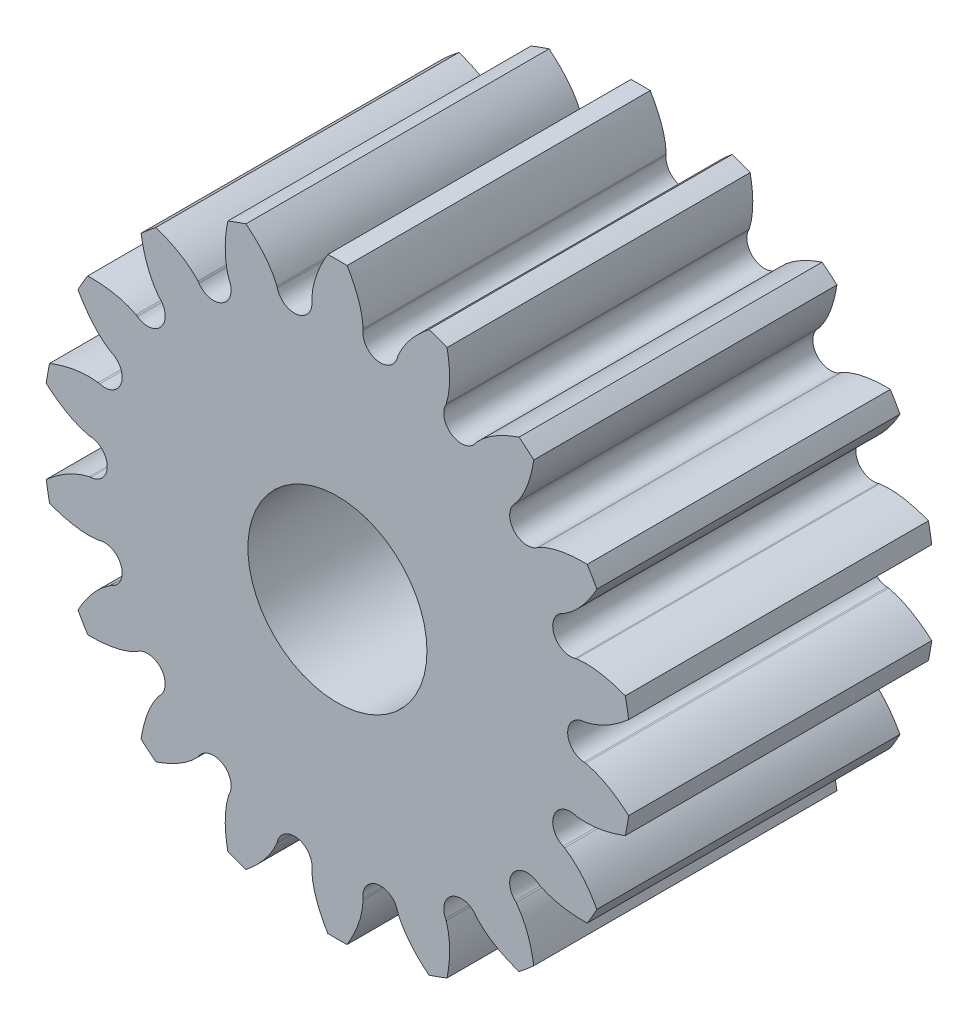
from build123d import *

# Parameters (mm, degrees)
SKETCH3_R                           = 2.286
SKETCH3_R_2                         = 0.889
BASE_DEPTH                          = 3.0099
HALF_TOOTH_DEPTH                    = 3.0099
PATTERN_OF_HALF_TOOTH_COUNT         = 18
PATTERN_OF_HALF_TOOTH_COPY_1_DEPTH  = 3.0099
PATTERN_OF_HALF_TOOTH_COPY_2_DEPTH  = 3.0099
PATTERN_OF_HALF_TOOTH_COPY_3_DEPTH  = 3.0099
PATTERN_OF_HALF_TOOTH_COPY_4_DEPTH  = 3.0099
PATTERN_OF_HALF_TOOTH_COPY_5_DEPTH  = 3.0099
PATTERN_OF_HALF_TOOTH_COPY_6_DEPTH  = 3.0099
PATTERN_OF_HALF_TOOTH_COPY_7_DEPTH  = 3.0099
PATTERN_OF_HALF_TOOTH_COPY_8_DEPTH  = 3.0099
PATTERN_OF_HALF_TOOTH_COPY_9_DEPTH  = 3.0099
PATTERN_OF_HALF_TOOTH_COPY_10_DEPTH = 3.0099
PATTERN_OF_HALF_TOOTH_COPY_11_DEPTH = 3.0099
PATTERN_OF_HALF_TOOTH_COPY_12_DEPTH = 3.0099
PATTERN_OF_HALF_TOOTH_COPY_13_DEPTH = 3.0099
PATTERN_OF_HALF_TOOTH_COPY_14_DEPTH = 3.0099
PATTERN_OF_HALF_TOOTH_COPY_15_DEPTH = 3.0099
PATTERN_OF_HALF_TOOTH_COPY_16_DEPTH = 3.0099
PATTERN_OF_HALF_TOOTH_COPY_17_DEPTH = 3.0099


with BuildPart() as part:
    # Sketch3 → Base (new body)
    with BuildSketch(Plane.XY):
        Circle(SKETCH3_R)
        Circle(SKETCH3_R_2, mode=Mode.SUBTRACT)
    extrude(amount=BASE_DEPTH)

    # Sketch2 → Half tooth (add)
    with BuildSketch(Plane.XY):
        with BuildLine():
            Line((0, 2.921), (0, 2.286))
            ThreePointArc((0, 2.286), (0.199238028, 2.27730108), (0.396959734, 2.251270523))
            ThreePointArc((0.396959734, 2.251270523), (0.28773176, 2.318156306), (0.253382626, 2.441544292))
            Line((0.253382626, 2.441544292), (0.255003353, 2.457161288))
            add(Edge.make_bspline(
                [(0.255003353, 2.457161288), (0.25245669, 2.511970923), (0.22493294, 2.674677864), (0.152013752, 2.825486334), (0.095650308, 2.91943351)],
                knots=[0, 0, 0, 0, 0.332628043, 1, 1, 1, 1], degree=3))
            ThreePointArc((0.095650308, 2.91943351), (0.047831567, 2.920608351), (0, 2.921))
        make_face()
    half_tooth = extrude(amount=HALF_TOOTH_DEPTH)

    # Mirror of half tooth: Half tooth across plane
    add(half_tooth.mirror(Plane.ZY))

    # Pattern of half tooth: Half tooth ×18 about axis
    pattern_of_half_tooth_axis = Axis((0, 0, 3.0099), (0, 0, 1))
    for i in range(1, PATTERN_OF_HALF_TOOTH_COUNT):
        add(half_tooth.rotate(pattern_of_half_tooth_axis, i * 360 / PATTERN_OF_HALF_TOOTH_COUNT))

    # Pattern of half tooth copy 1 sketch → Pattern of half tooth copy 1 (add)
    with BuildSketch(Plane(origin=(0, 0, 0), x_dir=(-0.939692621, -0.342020143, 0), z_dir=(0, 0, 1))):
        with BuildLine():
            Line((0, -2.921), (0, -2.286))
            ThreePointArc((0, -2.286), (0.199238028, -2.27730108), (0.396959734, -2.251270523))
            ThreePointArc((0.396959734, -2.251270523), (0.28773176, -2.318156306), (0.253382626, -2.441544292))
            Line((0.253382626, -2.441544292), (0.255003353, -2.457161288))
            add(Edge.make_bspline(
                [(0.255003353, -2.457161288), (0.25245669, -2.511970923), (0.22493294, -2.674677864), (0.152013752, -2.825486334), (0.095650308, -2.91943351)],
                knots=[0, 0, 0, 0, 0.332628043, 1, 1, 1, 1], degree=3))
            ThreePointArc((0.095650308, -2.91943351), (0.047831567, -2.920608351), (0, -2.921))
        make_face()
    extrude(amount=PATTERN_OF_HALF_TOOTH_COPY_1_DEPTH)

    # Pattern of half tooth copy 2 sketch → Pattern of half tooth copy 2 (add)
    with BuildSketch(Plane(origin=(0, 0, 0), x_dir=(-0.766044443, -0.64278761, 0), z_dir=(0, 0, 1))):
        with BuildLine():
            Line((0, -2.921), (0, -2.286))
            ThreePointArc((0, -2.286), (0.199238028, -2.27730108), (0.396959734, -2.251270523))
            ThreePointArc((0.396959734, -2.251270523), (0.28773176, -2.318156306), (0.253382626, -2.441544292))
            Line((0.253382626, -2.441544292), (0.255003353, -2.457161288))
            add(Edge.make_bspline(
                [(0.255003353, -2.457161288), (0.25245669, -2.511970923), (0.22493294, -2.674677864), (0.152013752, -2.825486334), (0.095650308, -2.91943351)],
                knots=[0, 0, 0, 0, 0.332628043, 1, 1, 1, 1], degree=3))
            ThreePointArc((0.095650308, -2.91943351), (0.047831567, -2.920608351), (0, -2.921))
        make_face()
    extrude(amount=PATTERN_OF_HALF_TOOTH_COPY_2_DEPTH)

    # Pattern of half tooth copy 3 sketch → Pattern of half tooth copy 3 (add)
    with BuildSketch(Plane(origin=(0, 0, 0), x_dir=(-0.5, -0.866025404, 0), z_dir=(0, 0, 1))):
        with BuildLine():
            Line((0, -2.921), (0, -2.286))
            ThreePointArc((0, -2.286), (0.199238028, -2.27730108), (0.396959734, -2.251270523))
            ThreePointArc((0.396959734, -2.251270523), (0.28773176, -2.318156306), (0.253382626, -2.441544292))
            Line((0.253382626, -2.441544292), (0.255003353, -2.457161288))
            add(Edge.make_bspline(
                [(0.255003353, -2.457161288), (0.25245669, -2.511970923), (0.22493294, -2.674677864), (0.152013752, -2.825486334), (0.095650308, -2.91943351)],
                knots=[0, 0, 0, 0, 0.332628043, 1, 1, 1, 1], degree=3))
            ThreePointArc((0.095650308, -2.91943351), (0.047831567, -2.920608351), (0, -2.921))
        make_face()
    extrude(amount=PATTERN_OF_HALF_TOOTH_COPY_3_DEPTH)

    # Pattern of half tooth copy 4 sketch → Pattern of half tooth copy 4 (add)
    with BuildSketch(Plane(origin=(0, 0, 0), x_dir=(-0.173648178, -0.984807753, 0), z_dir=(0, 0, 1))):
        with BuildLine():
            Line((0, -2.921), (0, -2.286))
            ThreePointArc((0, -2.286), (0.199238028, -2.27730108), (0.396959734, -2.251270523))
            ThreePointArc((0.396959734, -2.251270523), (0.28773176, -2.318156306), (0.253382626, -2.441544292))
            Line((0.253382626, -2.441544292), (0.255003353, -2.457161288))
            add(Edge.make_bspline(
                [(0.255003353, -2.457161288), (0.25245669, -2.511970923), (0.22493294, -2.674677864), (0.152013752, -2.825486334), (0.095650308, -2.91943351)],
                knots=[0, 0, 0, 0, 0.332628043, 1, 1, 1, 1], degree=3))
            ThreePointArc((0.095650308, -2.91943351), (0.047831567, -2.920608351), (0, -2.921))
        make_face()
    extrude(amount=PATTERN_OF_HALF_TOOTH_COPY_4_DEPTH)

    # Pattern of half tooth copy 5 sketch → Pattern of half tooth copy 5 (add)
    with BuildSketch(Plane(origin=(0, 0, 0), x_dir=(0.173648178, -0.984807753, 0), z_dir=(0, 0, 1))):
        with BuildLine():
            Line((0, -2.921), (0, -2.286))
            ThreePointArc((0, -2.286), (0.199238028, -2.27730108), (0.396959734, -2.251270523))
            ThreePointArc((0.396959734, -2.251270523), (0.28773176, -2.318156306), (0.253382626, -2.441544292))
            Line((0.253382626, -2.441544292), (0.255003353, -2.457161288))
            add(Edge.make_bspline(
                [(0.255003353, -2.457161288), (0.25245669, -2.511970923), (0.22493294, -2.674677864), (0.152013752, -2.825486334), (0.095650308, -2.91943351)],
                knots=[0, 0, 0, 0, 0.332628043, 1, 1, 1, 1], degree=3))
            ThreePointArc((0.095650308, -2.91943351), (0.047831567, -2.920608351), (0, -2.921))
        make_face()
    extrude(amount=PATTERN_OF_HALF_TOOTH_COPY_5_DEPTH)

    # Pattern of half tooth copy 6 sketch → Pattern of half tooth copy 6 (add)
    with BuildSketch(Plane(origin=(0, 0, 0), x_dir=(0.5, -0.866025404, 0), z_dir=(0, 0, 1))):
        with BuildLine():
            Line((0, -2.921), (0, -2.286))
            ThreePointArc((0, -2.286), (0.199238028, -2.27730108), (0.396959734, -2.251270523))
            ThreePointArc((0.396959734, -2.251270523), (0.28773176, -2.318156306), (0.253382626, -2.441544292))
            Line((0.253382626, -2.441544292), (0.255003353, -2.457161288))
            add(Edge.make_bspline(
                [(0.255003353, -2.457161288), (0.25245669, -2.511970923), (0.22493294, -2.674677864), (0.152013752, -2.825486334), (0.095650308, -2.91943351)],
                knots=[0, 0, 0, 0, 0.332628043, 1, 1, 1, 1], degree=3))
            ThreePointArc((0.095650308, -2.91943351), (0.047831567, -2.920608351), (0, -2.921))
        make_face()
    extrude(amount=PATTERN_OF_HALF_TOOTH_COPY_6_DEPTH)

    # Pattern of half tooth copy 7 sketch → Pattern of half tooth copy 7 (add)
    with BuildSketch(Plane(origin=(0, 0, 0), x_dir=(0.766044443, -0.64278761, 0), z_dir=(0, 0, 1))):
        with BuildLine():
            Line((0, -2.921), (0, -2.286))
            ThreePointArc((0, -2.286), (0.199238028, -2.27730108), (0.396959734, -2.251270523))
            ThreePointArc((0.396959734, -2.251270523), (0.28773176, -2.318156306), (0.253382626, -2.441544292))
            Line((0.253382626, -2.441544292), (0.255003353, -2.457161288))
            add(Edge.make_bspline(
                [(0.255003353, -2.457161288), (0.25245669, -2.511970923), (0.22493294, -2.674677864), (0.152013752, -2.825486334), (0.095650308, -2.91943351)],
                knots=[0, 0, 0, 0, 0.332628043, 1, 1, 1, 1], degree=3))
            ThreePointArc((0.095650308, -2.91943351), (0.047831567, -2.920608351), (0, -2.921))
        make_face()
    extrude(amount=PATTERN_OF_HALF_TOOTH_COPY_7_DEPTH)

    # Pattern of half tooth copy 8 sketch → Pattern of half tooth copy 8 (add)
    with BuildSketch(Plane(origin=(0, 0, 0), x_dir=(0.939692621, -0.342020143, 0), z_dir=(0, 0, 1))):
        with BuildLine():
            Line((0, -2.921), (0, -2.286))
            ThreePointArc((0, -2.286), (0.199238028, -2.27730108), (0.396959734, -2.251270523))
            ThreePointArc((0.396959734, -2.251270523), (0.28773176, -2.318156306), (0.253382626, -2.441544292))
            Line((0.253382626, -2.441544292), (0.255003353, -2.457161288))
            add(Edge.make_bspline(
                [(0.255003353, -2.457161288), (0.25245669, -2.511970923), (0.22493294, -2.674677864), (0.152013752, -2.825486334), (0.095650308, -2.91943351)],
                knots=[0, 0, 0, 0, 0.332628043, 1, 1, 1, 1], degree=3))
            ThreePointArc((0.095650308, -2.91943351), (0.047831567, -2.920608351), (0, -2.921))
        make_face()
    extrude(amount=PATTERN_OF_HALF_TOOTH_COPY_8_DEPTH)

    # Pattern of half tooth copy 9 sketch → Pattern of half tooth copy 9 (add)
    with BuildSketch(Plane.XY):
        with BuildLine():
            Line((0, -2.921), (0, -2.286))
            ThreePointArc((0, -2.286), (0.199238028, -2.27730108), (0.396959734, -2.251270523))
            ThreePointArc((0.396959734, -2.251270523), (0.28773176, -2.318156306), (0.253382626, -2.441544292))
            Line((0.253382626, -2.441544292), (0.255003353, -2.457161288))
            add(Edge.make_bspline(
                [(0.255003353, -2.457161288), (0.25245669, -2.511970923), (0.22493294, -2.674677864), (0.152013752, -2.825486334), (0.095650308, -2.91943351)],
                knots=[0, 0, 0, 0, 0.332628043, 1, 1, 1, 1], degree=3))
            ThreePointArc((0.095650308, -2.91943351), (0.047831567, -2.920608351), (0, -2.921))
        make_face()
    extrude(amount=PATTERN_OF_HALF_TOOTH_COPY_9_DEPTH)

    # Pattern of half tooth copy 10 sketch → Pattern of half tooth copy 10 (add)
    with BuildSketch(Plane(origin=(0, 0, 0), x_dir=(0.939692621, 0.342020143, 0), z_dir=(0, 0, 1))):
        with BuildLine():
            Line((0, -2.921), (0, -2.286))
            ThreePointArc((0, -2.286), (0.199238028, -2.27730108), (0.396959734, -2.251270523))
            ThreePointArc((0.396959734, -2.251270523), (0.28773176, -2.318156306), (0.253382626, -2.441544292))
            Line((0.253382626, -2.441544292), (0.255003353, -2.457161288))
            add(Edge.make_bspline(
                [(0.255003353, -2.457161288), (0.25245669, -2.511970923), (0.22493294, -2.674677864), (0.152013752, -2.825486334), (0.095650308, -2.91943351)],
                knots=[0, 0, 0, 0, 0.332628043, 1, 1, 1, 1], degree=3))
            ThreePointArc((0.095650308, -2.91943351), (0.047831567, -2.920608351), (0, -2.921))
        make_face()
    extrude(amount=PATTERN_OF_HALF_TOOTH_COPY_10_DEPTH)

    # Pattern of half tooth copy 11 sketch → Pattern of half tooth copy 11 (add)
    with BuildSketch(Plane(origin=(0, 0, 0), x_dir=(0.766044443, 0.64278761, 0), z_dir=(0, 0, 1))):
        with BuildLine():
            Line((0, -2.921), (0, -2.286))
            ThreePointArc((0, -2.286), (0.199238028, -2.27730108), (0.396959734, -2.251270523))
            ThreePointArc((0.396959734, -2.251270523), (0.28773176, -2.318156306), (0.253382626, -2.441544292))
            Line((0.253382626, -2.441544292), (0.255003353, -2.457161288))
            add(Edge.make_bspline(
                [(0.255003353, -2.457161288), (0.25245669, -2.511970923), (0.22493294, -2.674677864), (0.152013752, -2.825486334), (0.095650308, -2.91943351)],
                knots=[0, 0, 0, 0, 0.332628043, 1, 1, 1, 1], degree=3))
            ThreePointArc((0.095650308, -2.91943351), (0.047831567, -2.920608351), (0, -2.921))
        make_face()
    extrude(amount=PATTERN_OF_HALF_TOOTH_COPY_11_DEPTH)

    # Pattern of half tooth copy 12 sketch → Pattern of half tooth copy 12 (add)
    with BuildSketch(Plane(origin=(0, 0, 0), x_dir=(0.5, 0.866025404, 0), z_dir=(0, 0, 1))):
        with BuildLine():
            Line((0, -2.921), (0, -2.286))
            ThreePointArc((0, -2.286), (0.199238028, -2.27730108), (0.396959734, -2.251270523))
            ThreePointArc((0.396959734, -2.251270523), (0.28773176, -2.318156306), (0.253382626, -2.441544292))
            Line((0.253382626, -2.441544292), (0.255003353, -2.457161288))
            add(Edge.make_bspline(
                [(0.255003353, -2.457161288), (0.25245669, -2.511970923), (0.22493294, -2.674677864), (0.152013752, -2.825486334), (0.095650308, -2.91943351)],
                knots=[0, 0, 0, 0, 0.332628043, 1, 1, 1, 1], degree=3))
            ThreePointArc((0.095650308, -2.91943351), (0.047831567, -2.920608351), (0, -2.921))
        make_face()
    extrude(amount=PATTERN_OF_HALF_TOOTH_COPY_12_DEPTH)

    # Pattern of half tooth copy 13 sketch → Pattern of half tooth copy 13 (add)
    with BuildSketch(Plane(origin=(0, 0, 0), x_dir=(0.173648178, 0.984807753, 0), z_dir=(0, 0, 1))):
        with BuildLine():
            Line((0, -2.921), (0, -2.286))
            ThreePointArc((0, -2.286), (0.199238028, -2.27730108), (0.396959734, -2.251270523))
            ThreePointArc((0.396959734, -2.251270523), (0.28773176, -2.318156306), (0.253382626, -2.441544292))
            Line((0.253382626, -2.441544292), (0.255003353, -2.457161288))
            add(Edge.make_bspline(
                [(0.255003353, -2.457161288), (0.25245669, -2.511970923), (0.22493294, -2.674677864), (0.152013752, -2.825486334), (0.095650308, -2.91943351)],
                knots=[0, 0, 0, 0, 0.332628043, 1, 1, 1, 1], degree=3))
            ThreePointArc((0.095650308, -2.91943351), (0.047831567, -2.920608351), (0, -2.921))
        make_face()
    extrude(amount=PATTERN_OF_HALF_TOOTH_COPY_13_DEPTH)

    # Pattern of half tooth copy 14 sketch → Pattern of half tooth copy 14 (add)
    with BuildSketch(Plane(origin=(0, 0, 0), x_dir=(-0.173648178, 0.984807753, 0), z_dir=(0, 0, 1))):
        with BuildLine():
            Line((0, -2.921), (0, -2.286))
            ThreePointArc((0, -2.286), (0.199238028, -2.27730108), (0.396959734, -2.251270523))
            ThreePointArc((0.396959734, -2.251270523), (0.28773176, -2.318156306), (0.253382626, -2.441544292))
            Line((0.253382626, -2.441544292), (0.255003353, -2.457161288))
            add(Edge.make_bspline(
                [(0.255003353, -2.457161288), (0.25245669, -2.511970923), (0.22493294, -2.674677864), (0.152013752, -2.825486334), (0.095650308, -2.91943351)],
                knots=[0, 0, 0, 0, 0.332628043, 1, 1, 1, 1], degree=3))
            ThreePointArc((0.095650308, -2.91943351), (0.047831567, -2.920608351), (0, -2.921))
        make_face()
    extrude(amount=PATTERN_OF_HALF_TOOTH_COPY_14_DEPTH)

    # Pattern of half tooth copy 15 sketch → Pattern of half tooth copy 15 (add)
    with BuildSketch(Plane(origin=(0, 0, 0), x_dir=(-0.5, 0.866025404, 0), z_dir=(0, 0, 1))):
        with BuildLine():
            Line((0, -2.921), (0, -2.286))
            ThreePointArc((0, -2.286), (0.199238028, -2.27730108), (0.396959734, -2.251270523))
            ThreePointArc((0.396959734, -2.251270523), (0.28773176, -2.318156306), (0.253382626, -2.441544292))
            Line((0.253382626, -2.441544292), (0.255003353, -2.457161288))
            add(Edge.make_bspline(
                [(0.255003353, -2.457161288), (0.25245669, -2.511970923), (0.22493294, -2.674677864), (0.152013752, -2.825486334), (0.095650308, -2.91943351)],
                knots=[0, 0, 0, 0, 0.332628043, 1, 1, 1, 1], degree=3))
            ThreePointArc((0.095650308, -2.91943351), (0.047831567, -2.920608351), (0, -2.921))
        make_face()
    extrude(amount=PATTERN_OF_HALF_TOOTH_COPY_15_DEPTH)

    # Pattern of half tooth copy 16 sketch → Pattern of half tooth copy 16 (add)
    with BuildSketch(Plane(origin=(0, 0, 0), x_dir=(-0.766044443, 0.64278761, 0), z_dir=(0, 0, 1))):
        with BuildLine():
            Line((0, -2.921), (0, -2.286))
            ThreePointArc((0, -2.286), (0.199238028, -2.27730108), (0.396959734, -2.251270523))
            ThreePointArc((0.396959734, -2.251270523), (0.28773176, -2.318156306), (0.253382626, -2.441544292))
            Line((0.253382626, -2.441544292), (0.255003353, -2.457161288))
            add(Edge.make_bspline(
                [(0.255003353, -2.457161288), (0.25245669, -2.511970923), (0.22493294, -2.674677864), (0.152013752, -2.825486334), (0.095650308, -2.91943351)],
                knots=[0, 0, 0, 0, 0.332628043, 1, 1, 1, 1], degree=3))
            ThreePointArc((0.095650308, -2.91943351), (0.047831567, -2.920608351), (0, -2.921))
        make_face()
    extrude(amount=PATTERN_OF_HALF_TOOTH_COPY_16_DEPTH)

    # Pattern of half tooth copy 17 sketch → Pattern of half tooth copy 17 (add)
    with BuildSketch(Plane(origin=(0, 0, 0), x_dir=(-0.939692621, 0.342020143, 0), z_dir=(0, 0, 1))):
        with BuildLine():
            Line((0, -2.921), (0, -2.286))
            ThreePointArc((0, -2.286), (0.199238028, -2.27730108), (0.396959734, -2.251270523))
            ThreePointArc((0.396959734, -2.251270523), (0.28773176, -2.318156306), (0.253382626, -2.441544292))
            Line((0.253382626, -2.441544292), (0.255003353, -2.457161288))
            add(Edge.make_bspline(
                [(0.255003353, -2.457161288), (0.25245669, -2.511970923), (0.22493294, -2.674677864), (0.152013752, -2.825486334), (0.095650308, -2.91943351)],
                knots=[0, 0, 0, 0, 0.332628043, 1, 1, 1, 1], degree=3))
            ThreePointArc((0.095650308, -2.91943351), (0.047831567, -2.920608351), (0, -2.921))
        make_face()
    extrude(amount=PATTERN_OF_HALF_TOOTH_COPY_17_DEPTH)


solid = part.part
